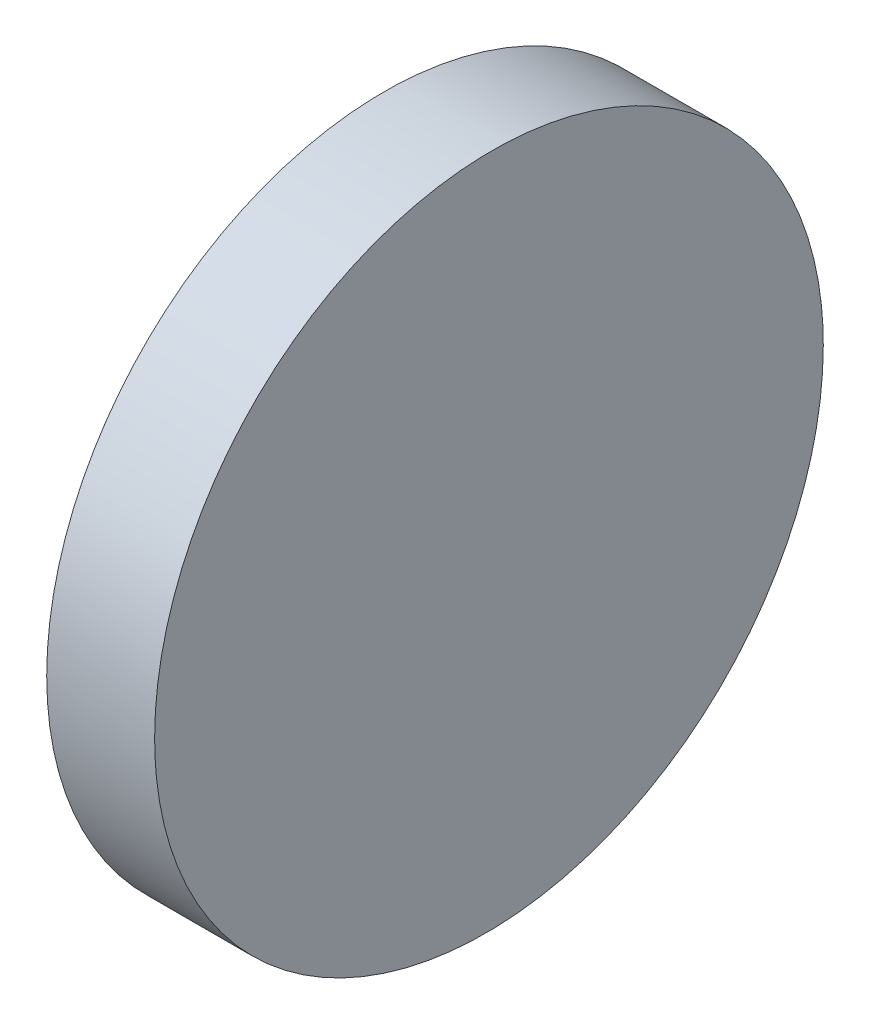
from build123d import *

# Parameters (mm, degrees)
EXTRUDE_1_DEPTH     = 50
CUT_EXTRUDE_2_DEPTH = 12.5


with BuildPart() as part:
    # 草图1 → 凸台-拉伸1 (new body)
    with BuildSketch(Plane(origin=(0, 0, 0), x_dir=(1, 0, 0), z_dir=(0, 1, 0))):
        Polygon((0, 25), (0, -25), (8, -25), (7.56365661, 25), align=None)
    extrude(amount=EXTRUDE_1_DEPTH)

    # 草图5 → 切除-拉伸2 (cut)
    with BuildSketch(Plane.ZY):
        with BuildLine():
            Line((-25, 50), (-25, 25))
            ThreePointArc((-25, 25), (-17.67766952, 42.677669539), (2.6e-08, 50))
            Line((2.6e-08, 50), (-25, 50))
        make_face()
        with BuildLine():
            Line((-25, 25), (-25, 0))
            Line((-25, 0), (-5.8e-08, 0))
            ThreePointArc((-5.8e-08, 0), (-17.67766955, 7.322330491), (-25, 25))
        make_face()
        with BuildLine():
            ThreePointArc((25, 25), (17.677669509, 7.32233045), (-5.8e-08, 0))
            Line((-5.8e-08, 0), (25, 0))
            Line((25, 0), (25, 25))
        make_face()
        with BuildLine():
            ThreePointArc((2.6e-08, 50), (17.677669539, 42.67766952), (25, 25))
            Line((25, 25), (25, 50))
            Line((25, 50), (2.6e-08, 50))
        make_face()
    extrude(amount=-CUT_EXTRUDE_2_DEPTH, mode=Mode.SUBTRACT)


solid = part.part
